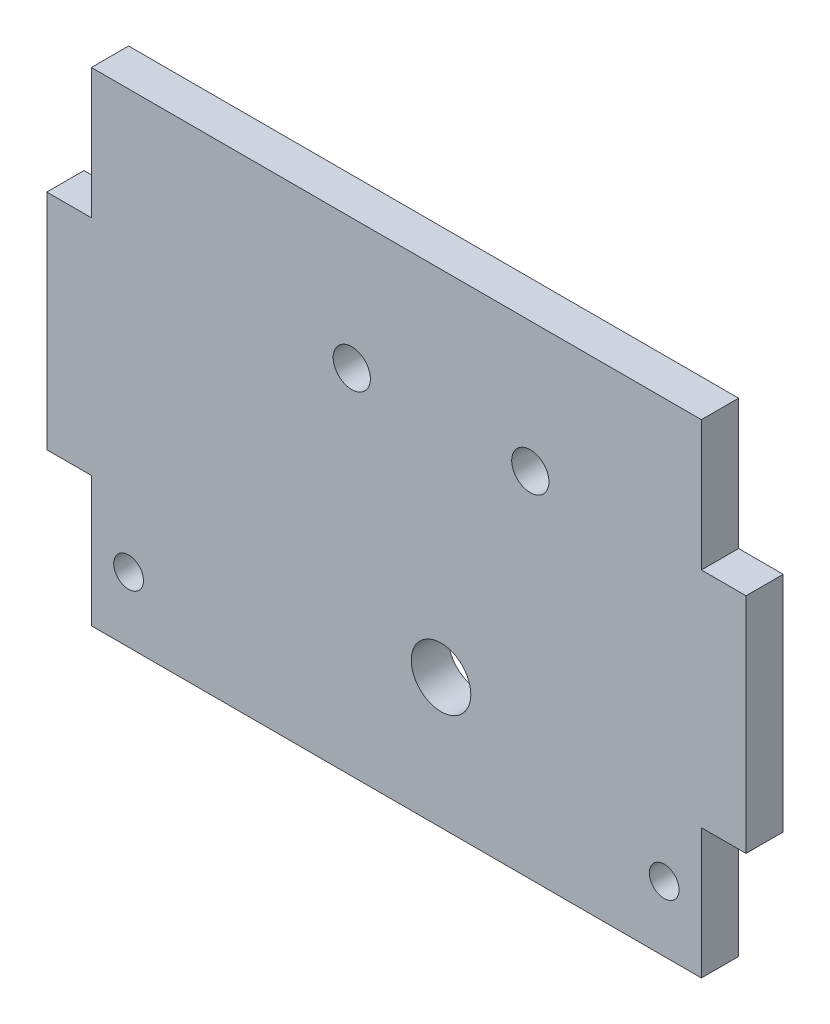
from build123d import *

# Parameters (mm, degrees)
SKETCH2_W            = 50
SKETCH2_H            = 65
SKETCH2_R            = 2
SKETCH2_R_2          = 4
BOSS_EXTRUDE1_DEPTH  = 5
SKETCH3_W            = 21
SKETCH3_H            = 65
BOSS_EXTRUDE2_DEPTH  = 5
SKETCH4_W            = 1
SKETCH4_H            = 65
BOSS_EXTRUDE3_DEPTH  = 5
BOSS_EXTRUDE4_DEPTH  = 5
SKETCH6_R            = 2
CUT_EXTRUDE1_DEPTH   = 59
SKETCH7_R            = 1.5
CUT_EXTRUDE2_DEPTH   = 10
SKETCH7_4_R          = 1.5
CUT_EXTRUDE3_DEPTH   = 10
SKETCH7_5_R          = 1.5
BOSS_EXTRUDE5_DEPTH  = 5
SKETCH8_R            = 2
CUT_EXTRUDE4_DEPTH   = 10
SKETCH9_R            = 2.5
CUT_EXTRUDE5_DEPTH   = 10
SKETCH10_R           = 2.5
BOSS_EXTRUDE6_DEPTH  = 5
SKETCH10_4_R         = 2.5
CUT_EXTRUDE6_DEPTH   = 10
SKETCH11_W           = 72
SKETCH11_H           = 5
BOSS_EXTRUDE7_DEPTH  = 10
SKETCH12_W           = 5
SKETCH12_H           = 17.5
BOSS_EXTRUDE8_DEPTH  = 10
SKETCH14_W           = 5
SKETCH14_H           = 27.5
BOSS_EXTRUDE9_DEPTH  = 10
SKETCH13_W           = 5
SKETCH13_H           = 30
BOSS_EXTRUDE10_DEPTH = 10
SKETCH17_R           = 2
BOSS_EXTRUDE11_DEPTH = 5
SKETCH17_3_R         = 2
CUT_EXTRUDE7_DEPTH   = 10
SKETCH18_W           = 82
SKETCH18_H           = 5
CUT_EXTRUDE8_DEPTH   = 10
SKETCH19_R           = 2.5
BOSS_EXTRUDE12_DEPTH = 5
CUT_EXTRUDE9_DEPTH   = 10


with BuildPart() as part:
    # Sketch2 → Boss-Extrude1 (new body)
    with BuildSketch(Plane.XY):
        with Locations((25, 32.5)):
            Rectangle(SKETCH2_W, SKETCH2_H)
        with Locations((25, 59.5)):
            Circle(SKETCH2_R, mode=Mode.SUBTRACT)
        with Locations((13, 47.5)):
            Circle(SKETCH2_R, mode=Mode.SUBTRACT)
        with Locations((37, 47.5)):
            Circle(SKETCH2_R, mode=Mode.SUBTRACT)
        with Locations((25, 17.5)):
            Circle(SKETCH2_R_2, mode=Mode.SUBTRACT)
    extrude(amount=BOSS_EXTRUDE1_DEPTH)

    # Sketch3 → Boss-Extrude2 (add)
    with BuildSketch(Plane.XY.offset(5)):
        with Locations((-10.5, 32.5)):
            Rectangle(SKETCH3_W, SKETCH3_H)
    extrude(amount=-BOSS_EXTRUDE2_DEPTH)

    # Sketch4 → Boss-Extrude3 (add)
    with BuildSketch(Plane.XY.offset(5)):
        with Locations((-21.5, 32.5)):
            Rectangle(SKETCH4_W, SKETCH4_H)
    extrude(amount=-BOSS_EXTRUDE3_DEPTH)

    # Sketch5 → Boss-Extrude4 (add)
    with BuildSketch(Plane.XY.offset(5)):
        Polygon((-22, 17.5), (-22, 32.5), (-22, 47.5), (-28, 47.5), (-28, 17.5), align=None)
        Polygon((56, 17.5), (56, 47.5), (50, 47.5), (50, 32.5), (50, 17.5), align=None)
    extrude(amount=-BOSS_EXTRUDE4_DEPTH)

    # Sketch6 → Cut-Extrude1 (cut)
    with BuildSketch(Plane.XY.offset(5)):
        with Locations((25, 35.5)):
            Circle(SKETCH6_R)
    extrude(amount=-CUT_EXTRUDE1_DEPTH, mode=Mode.SUBTRACT)

    # Sketch7 → Cut-Extrude2 (cut)
    with BuildSketch(Plane.XY.offset(5)):
        with Locations((-17, 56.25)):
            Circle(SKETCH7_R)
        with Locations((45, 56.25)):
            Circle(SKETCH7_R)
    extrude(amount=-CUT_EXTRUDE2_DEPTH, mode=Mode.SUBTRACT)

    # Sketch7_4 → Cut-Extrude3 (cut)
    with BuildSketch(Plane.XY.offset(5)):
        with Locations((45, 8.75)):
            Circle(SKETCH7_4_R)
        with Locations((-17, 8.75)):
            Circle(SKETCH7_4_R)
    extrude(amount=-CUT_EXTRUDE3_DEPTH, mode=Mode.SUBTRACT)

    # Sketch7_5 → Boss-Extrude5 (add)
    with BuildSketch(Plane.XY.offset(5)):
        with Locations((-17, 56.25)):
            Circle(SKETCH7_5_R)
        with Locations((45, 56.25)):
            Circle(SKETCH7_5_R)
    extrude(amount=-BOSS_EXTRUDE5_DEPTH)

    # Sketch8 → Cut-Extrude4 (cut)
    with BuildSketch(Plane.XY.offset(5)):
        with Locations((-17, 8.75)):
            Circle(SKETCH8_R)
        with Locations((45, 8.75)):
            Circle(SKETCH8_R)
    extrude(amount=-CUT_EXTRUDE4_DEPTH, mode=Mode.SUBTRACT)

    # Sketch9 → Cut-Extrude5 (cut)
    with BuildSketch(Plane.XY.offset(5)):
        with Locations((25, 59.5)):
            Circle(SKETCH9_R)
        with Locations((25, 35.5)):
            Circle(SKETCH9_R)
        with Locations((13, 47.5)):
            Circle(SKETCH9_R)
        with Locations((37, 47.5)):
            Circle(SKETCH9_R)
    extrude(amount=-CUT_EXTRUDE5_DEPTH, mode=Mode.SUBTRACT)

    # Sketch10 → Boss-Extrude6 (add)
    with BuildSketch(Plane.XY.offset(5)):
        with BuildLine():
            Line((10.5, 47.5), (13, 47.5))
            Line((13, 47.5), (15.5, 47.5))
            ThreePointArc((15.5, 47.5), (13, 50), (10.5, 47.5))
        make_face()
        with BuildLine():
            Line((15.5, 47.5), (13, 47.5))
            Line((13, 47.5), (10.5, 47.5))
            ThreePointArc((10.5, 47.5), (13, 45), (15.5, 47.5))
        make_face()
        with Locations((25, 59.5)):
            Circle(SKETCH10_R)
        with BuildLine():
            ThreePointArc((39.5, 47.5), (37, 50), (34.5, 47.5))
            Line((34.5, 47.5), (37, 47.5))
            Line((37, 47.5), (39.5, 47.5))
        make_face()
        with BuildLine():
            Line((37, 47.5), (34.5, 47.5))
            ThreePointArc((34.5, 47.5), (37, 45), (39.5, 47.5))
            Line((39.5, 47.5), (37, 47.5))
        make_face()
        with Locations((25, 35.5)):
            Circle(SKETCH10_R)
    extrude(amount=-BOSS_EXTRUDE6_DEPTH)

    # Sketch10_4 → Cut-Extrude6 (cut)
    with BuildSketch(Plane.XY.offset(5)):
        with Locations((6.5, 47.5)):
            Circle(SKETCH10_4_R)
        with Locations((43.5, 47.5)):
            Circle(SKETCH10_4_R)
    extrude(amount=-CUT_EXTRUDE6_DEPTH, mode=Mode.SUBTRACT)

    # Sketch11 → Boss-Extrude7 (add)
    with BuildSketch(Plane(origin=(0, 65, 0), x_dir=(1, 0, 0), z_dir=(0, 1, 0))):
        with Locations((14, -2.5)):
            Rectangle(SKETCH11_W, SKETCH11_H)
    extrude(amount=BOSS_EXTRUDE7_DEPTH)

    # Sketch12 → Boss-Extrude8 (add)
    with BuildSketch(Plane(origin=(50, 0, 0), x_dir=(0, 0, -1), z_dir=(1, 0, 0))):
        with Locations((-2.5, 8.75)):
            Rectangle(SKETCH12_W, SKETCH12_H)
    extrude(amount=BOSS_EXTRUDE8_DEPTH)

    # Sketch14 → Boss-Extrude9 (add)
    with BuildSketch(Plane(origin=(50, 0, 0), x_dir=(0, 0, -1), z_dir=(1, 0, 0))):
        with Locations((-2.5, 61.25)):
            Rectangle(SKETCH14_W, SKETCH14_H)
    extrude(amount=BOSS_EXTRUDE9_DEPTH)

    # Sketch13 → Boss-Extrude10 (add)
    with BuildSketch(Plane(origin=(56, 0, 0), x_dir=(0, 0, -1), z_dir=(1, 0, 0))):
        with Locations((-2.5, 32.5)):
            Rectangle(SKETCH13_W, SKETCH13_H)
    extrude(amount=BOSS_EXTRUDE10_DEPTH)

    # Sketch17 → Boss-Extrude11 (add)
    with BuildSketch(Plane.XY.offset(5)):
        with Locations((45, 8.75)):
            Circle(SKETCH17_R)
        with Locations((55, 8.75)):
            Circle(SKETCH17_R)
    extrude(amount=-BOSS_EXTRUDE11_DEPTH)

    # Sketch17_3 → Cut-Extrude7 (cut)
    with BuildSketch(Plane.XY.offset(5)):
        with Locations((55, 8.75)):
            Circle(SKETCH17_3_R)
    extrude(amount=-CUT_EXTRUDE7_DEPTH, mode=Mode.SUBTRACT)

    # Sketch18 → Cut-Extrude8 (cut)
    with BuildSketch(Plane(origin=(0, 75, 0), x_dir=(1, 0, 0), z_dir=(0, 1, 0))):
        with Locations((19, -2.5)):
            Rectangle(SKETCH18_W, SKETCH18_H)
    extrude(amount=-CUT_EXTRUDE8_DEPTH, mode=Mode.SUBTRACT)

    # Sketch19 → Boss-Extrude12 (add)
    with BuildSketch(Plane.XY.offset(5)):
        with Locations((6.5, 47.5)):
            Circle(SKETCH19_R)
        with Locations((13, 47.5)):
            Circle(SKETCH19_R)
        with Locations((37, 47.5)):
            Circle(SKETCH19_R)
        with Locations((43.5, 47.5)):
            Circle(SKETCH19_R)
    extrude(amount=-BOSS_EXTRUDE12_DEPTH)

    # Sketch19_3 → Cut-Extrude9 (cut)
    with BuildSketch(Plane.XY.offset(5)):
        with BuildLine():
            Line((10.5, 47.5), (13, 47.5))
            Line((13, 47.5), (15.5, 47.5))
            ThreePointArc((15.5, 47.5), (13, 50), (10.5, 47.5))
        make_face()
        with BuildLine():
            Line((15.5, 47.5), (13, 47.5))
            Line((13, 47.5), (10.5, 47.5))
            ThreePointArc((10.5, 47.5), (13, 45), (15.5, 47.5))
        make_face()
        with BuildLine():
            ThreePointArc((39.5, 47.5), (37, 50), (34.5, 47.5))
            Line((34.5, 47.5), (37, 47.5))
            Line((37, 47.5), (39.5, 47.5))
        make_face()
        with BuildLine():
            Line((37, 47.5), (34.5, 47.5))
            ThreePointArc((34.5, 47.5), (37, 45), (39.5, 47.5))
            Line((39.5, 47.5), (37, 47.5))
        make_face()
    extrude(amount=-CUT_EXTRUDE9_DEPTH, mode=Mode.SUBTRACT)


solid = part.part
